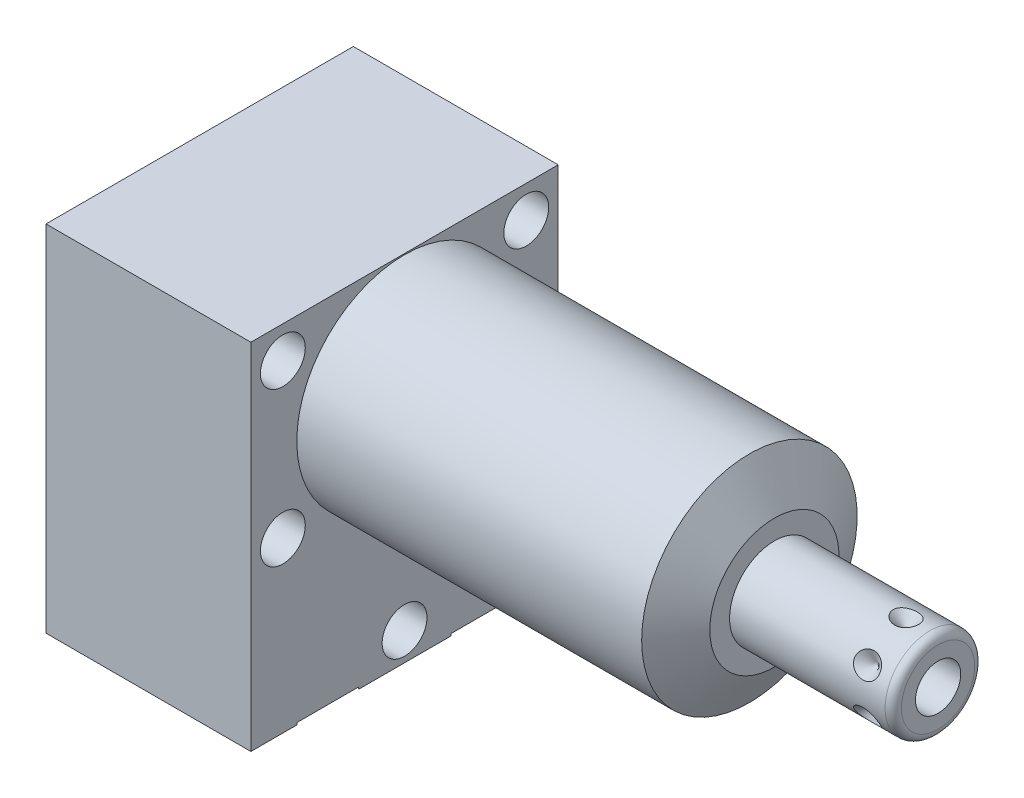
from build123d import *

# Parameters (mm, degrees)
SKETCH1_W           = 38.1
SKETCH1_H           = 43.942
EXTRUDE1_DEPTH      = 45.847
EXTRUDE1_DEPTH_BACK = 25.4
CUT_EXTRUDE1_REACH  = 47.847
SKETCH2_W           = 38.1
SKETCH2_H           = 43.942
SKETCH2_R           = 13.3604
SKETCH14_R          = 7.9375
CUT_EXTRUDE2_DEPTH  = 2.667
SKETCH10_R          = 6.4389
EXTRUDE2_DEPTH      = 1.651
SKETCH11_R          = 4.8006
EXTRUDE3_DEPTH      = 2.667
CIRPATTERN1_COUNT   = 6
HOLE1_D             = 5.5626
HOLE1_DEPTH         = 25.4


with BuildPart() as part:
    # Sketch1 → Extrude1 (new body, two sides)
    with BuildSketch(Plane(origin=(0, 0, 0), x_dir=(0, 0, -1), z_dir=(1, 0, 0))) as extrude1_sk:
        with Locations((0, -8.4836)):
            Rectangle(SKETCH1_W, SKETCH1_H)
    extrude(amount=EXTRUDE1_DEPTH)
    extrude(extrude1_sk.sketch, amount=-EXTRUDE1_DEPTH_BACK)

    # Sketch2 → Cut-Extrude1 (cut, up to next)
    with BuildSketch(Plane(origin=(0, 0, 0), x_dir=(0, 0, -1), z_dir=(1, 0, 0)), mode=Mode.PRIVATE) as cut_extrude1_sk1:
        with Locations((0, -8.4836)):
            Rectangle(SKETCH2_W, SKETCH2_H)
        Circle(SKETCH2_R, mode=Mode.SUBTRACT)
    cut_extrude1_tool1 = extrude(cut_extrude1_sk1.sketch, amount=CUT_EXTRUDE1_REACH, mode=Mode.PRIVATE) & part.part
    add(cut_extrude1_tool1.solids().sort_by_distance((0, 13.429241, 0))[0], mode=Mode.SUBTRACT)

    # Sketch3 → Cut-Revolve1 (revolve, cut)
    with BuildSketch(Plane.XY, mode=Mode.PRIVATE) as cut_revolve1_sk:
        Polygon((42.752748967, 13.3604), (45.847, 8.001), (45.847, 13.3604), align=None)
    revolve(cut_revolve1_sk.sketch.rotate(Axis((42.598036416, 0, 0), (1, 0, 0)), 90), axis=Axis((42.598036416, 0, 0), (1, 0, 0)), mode=Mode.SUBTRACT)  # turned: the seam where the file's is

    # S2D0002 → Cut-Revolve2 (revolve, cut)
    with BuildSketch(Plane(origin=(-22.733, -19.8374, 9.525), x_dir=(0, 1, 0), z_dir=(0, 0, 1)), mode=Mode.PRIVATE) as cut_revolve2_sk:
        Polygon((-0.8128, 0), (3.7338, 0), (3.293786662, -2.0701), (2.6416, -2.722286662), (2.6416, -13.97), (-0.8128, -13.97), align=None)
    revolve(cut_revolve2_sk.sketch.rotate(Axis((-8.0645, -20.6502, 9.525), (-1, 0, 0)), 90), axis=Axis((-8.0645, -20.6502, 9.525), (-1, 0, 0)), mode=Mode.SUBTRACT)  # turned: the seam where the file's is

    # Sketch5 → Cut-Revolve3 (revolve, cut)
    with BuildSketch(Plane(origin=(-22.733, -19.8374, -9.525), x_dir=(0, 1, 0), z_dir=(0, 0, 1)), mode=Mode.PRIVATE) as cut_revolve3_sk:
        Polygon((-0.8128, 0), (3.7338, 0), (3.293786662, -2.0701), (2.6416, -2.722286662), (2.6416, -13.97), (-0.8128, -13.97), align=None)
    revolve(cut_revolve3_sk.sketch.rotate(Axis((-8.0645, -20.6502, -9.525), (-1, 0, 0)), 90), axis=Axis((-8.0645, -20.6502, -9.525), (-1, 0, 0)), mode=Mode.SUBTRACT)  # turned: the seam where the file's is

    # Sketch14 → Cut-Extrude2 (cut)
    with BuildSketch(Plane.ZY.offset(25.4)):
        with Locations((-9.525, -20.6502)):
            Circle(SKETCH14_R)
        with Locations((9.525, -20.6502)):
            Circle(SKETCH14_R)
    extrude(amount=-CUT_EXTRUDE2_DEPTH, mode=Mode.SUBTRACT)

    # Sketch6 → Cut-Revolve4 (revolve, cut)
    with BuildSketch(Plane(origin=(-8.7376, -30.2006, 9.525), x_dir=(-1, 0, 0), z_dir=(0, 0, 1)), mode=Mode.PRIVATE) as cut_revolve4_sk:
        Polygon((6.18363, 0), (5.641036865, -2.5527), (4.97713, -3.216606865), (4.97713, -17.272), (0, -17.272), (0, 0), (0, 0.254), (9.52373, 0.254), (9.52373, 0), align=None)
    revolve(cut_revolve4_sk.sketch.rotate(Axis((-8.7376, -12.065, 9.525), (0, -1, 0)), 270), axis=Axis((-8.7376, -12.065, 9.525), (0, -1, 0)), mode=Mode.SUBTRACT)  # turned: the seam where the file's is

    # Sketch7 → Cut-Revolve5 (revolve, cut)
    with BuildSketch(Plane(origin=(-8.7376, -30.2006, -9.525), x_dir=(-1, 0, 0), z_dir=(0, 0, 1)), mode=Mode.PRIVATE) as cut_revolve5_sk:
        Polygon((6.1849, 0), (5.642306865, -2.5527), (4.9784, -3.216606865), (4.9784, -17.272), (0, -17.272), (0, 0), (0, 0.254), (9.52373, 0.254), (9.52373, 0), align=None)
    revolve(cut_revolve5_sk.sketch.rotate(Axis((-8.7376, -12.065, -9.525), (0, -1, 0)), 270), axis=Axis((-8.7376, -12.065, -9.525), (0, -1, 0)), mode=Mode.SUBTRACT)  # turned: the seam where the file's is

    # Sketch8 → Revolve1 (revolve)
    with BuildSketch(Plane.XY, mode=Mode.PRIVATE) as revolve1_sk:
        with BuildLine():
            Line((45.847, 0), (45.847, 5.55625))
            Line((45.847, 5.55625), (65.1256, 5.55625))
            ThreePointArc((65.1256, 5.55625), (65.84402049, 5.25867049), (66.1416, 4.54025))
            Line((66.1416, 4.54025), (66.1416, 0))
            Line((66.1416, 0), (45.847, 0))
        make_face()
    revolve(revolve1_sk.sketch.rotate(Axis((44.83227, 0, 0), (1, 0, 0)), 90), axis=Axis((44.83227, 0, 0), (1, 0, 0)))  # turned: the seam where the file's is

    # S2D0001 → Cut-Revolve6 (revolve, cut)
    with BuildSketch(Plane(origin=(66.1416, -2.8067, 0), x_dir=(0, -1, 0), z_dir=(0, 0, 1)), mode=Mode.PRIVATE) as cut_revolve6_sk:
        Polygon((0, 0), (0, -10.16), (-2.8067, -11.846435499), (-2.8067, 0), align=None)
    revolve(cut_revolve6_sk.sketch.rotate(Axis((53.702842726, 0, 0), (1, 0, 0)), 270), axis=Axis((53.702842726, 0, 0), (1, 0, 0)), mode=Mode.SUBTRACT)  # turned: the seam where the file's is

    # Sketch10 → Extrude2 (add)
    with BuildSketch(Plane(origin=(-25.4, -30.2006, 0), x_dir=(0, 0, -1), z_dir=(0, -1, 0))):
        with Locations(Location((-9.525, 16.6624, 0), (0, 0, 180))):  # turned: the seam where the file's is
            Circle(SKETCH10_R)
    extrude(amount=EXTRUDE2_DEPTH)

    # Sketch11 → Extrude3 (add)
    with BuildSketch(Plane.ZY.offset(22.733)):
        with Locations(Location((9.525, -20.6502, 0), (0, 0, 180))):  # turned: the seam where the file's is
            Circle(SKETCH11_R)
    extrude(amount=EXTRUDE3_DEPTH)

    # Sketch12 → Cut-Revolve7 (revolve, cut)
    with BuildSketch(Plane(origin=(62.1792, -5.55625, 0), x_dir=(-1, 0, 0), z_dir=(0, 0, 1)), mode=Mode.PRIVATE) as cut_revolve7_sk:
        Polygon((0, 0), (1.5875, 0), (0, -1.5875), align=None)
    cut_revolve7 = revolve(cut_revolve7_sk.sketch.rotate(Axis((62.1792, -2.12229387, 0), (0, -1, 0)), 90), axis=Axis((62.1792, -2.12229387, 0), (0, -1, 0)), mode=Mode.SUBTRACT)  # turned: the seam where the file's is

    # CirPattern1: Cut-Revolve7 ×6 about axis
    cirpattern1_axis = Axis((45.848, 0, 0), (-1, 0, 0))
    for i in range(1, CIRPATTERN1_COUNT):
        add(cut_revolve7.rotate(cirpattern1_axis, i * 360 / CIRPATTERN1_COUNT), mode=Mode.SUBTRACT)

    # Hole1
    with Locations(Plane(origin=(0, 0, 0), x_dir=(0, 0, -1), z_dir=(1, 0, 0))):
        with Locations((-15.0876, 9.525), (-15.0876, -9.525), (15.0876, 9.525), (15.0876, -9.525), (0, -26.9748)):
            Hole(HOLE1_D / 2, depth=HOLE1_DEPTH)


solid = part.part
